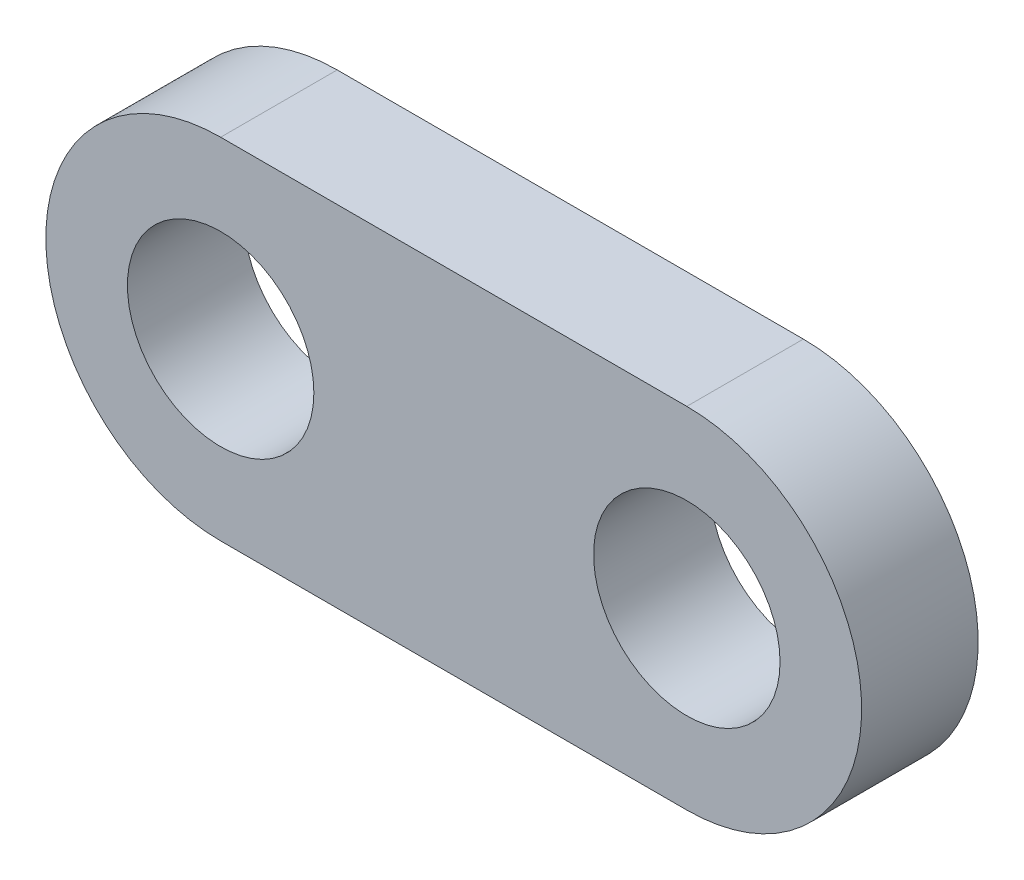
from build123d import *

# Parameters (mm, degrees)
SKETCH2_R           = 4
BOSS_EXTRUDE1_DEPTH = 5


with BuildPart() as part:
    # Sketch2 → Boss-Extrude1 (new body)
    with BuildSketch(Plane.XY):
        with BuildLine():
            Line((0, 7.5), (20, 7.5))
            ThreePointArc((20, 7.5), (27.5, 0), (20, -7.5))
            Line((20, -7.5), (0, -7.5))
            ThreePointArc((0, -7.5), (-7.5, 0), (0, 7.5))
        make_face()
        Circle(SKETCH2_R, mode=Mode.SUBTRACT)
        with Locations((20, 0)):
            Circle(SKETCH2_R, mode=Mode.SUBTRACT)
    extrude(amount=-BOSS_EXTRUDE1_DEPTH)


solid = part.part
